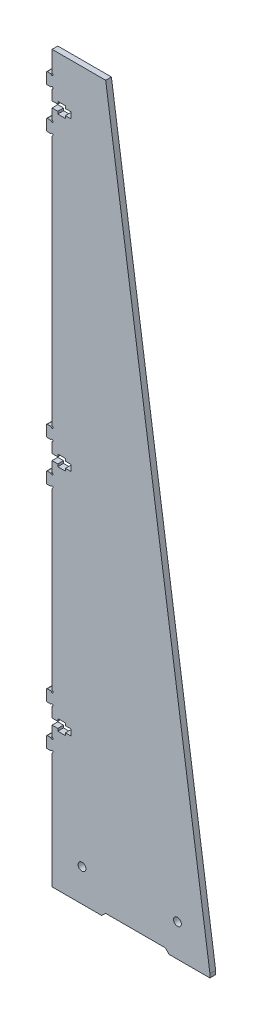
from build123d import *

# Parameters (mm, degrees)
MODEL_R                 = 2.05
SALIENTE_EXTRUIR1_DEPTH = 3


with BuildPart() as part:
    # Model → Saliente-Extruir1 (new body)
    with BuildSketch(Plane.XY):
        with BuildLine():
            Line((458.658091322, 643.996335498), (476.091013084, 643.996335498))
            Line((476.091013084, 643.996335498), (524.497055169, 308.953007972))
            Line((524.497055169, 308.953007972), (530.703308605, 265.996308498))
            Line((530.703308605, 265.996308498), (530.703308605, 263.996308498))
            Line((530.703308605, 263.996308498), (509.328287285, 263.996308498))
            Line((509.328287285, 263.996308498), (507.328283285, 265.996308498))
            Line((507.328283285, 265.996308498), (476.008092322, 265.996308498))
            Line((476.008092322, 265.996308498), (474.008092322, 263.996308498))
            Line((474.008092322, 263.996308498), (448.008092322, 263.996308498))
            Line((448.008092322, 263.996308498), (448.008095322, 324.530272498))
            ThreePointArc((448.008095322, 324.530272498), (448.075082188, 324.78027175), (448.258093826, 324.963284336))
            ThreePointArc((448.258093826, 324.963284336), (448.361645507, 325.749850684), (447.57507962, 325.646295498))
            ThreePointArc((447.57507962, 325.646295498), (447.39206666, 325.463282647), (447.142066322, 325.396295498))
            Line((447.142066322, 325.396295498), (445.508040322, 325.396292498))
            ThreePointArc((445.508040322, 325.396292498), (445.154486932, 325.542739108), (445.008040322, 325.896292498))
            Line((445.008040322, 325.896292498), (445.008040322, 330.896290498))
            ThreePointArc((445.008040322, 330.896290498), (445.154486932, 331.249843889), (445.508040322, 331.396290498))
            Line((445.508040322, 331.396290498), (447.142068322, 331.396290498))
            ThreePointArc((447.142068322, 331.396290498), (447.392067574, 331.329303632), (447.57508016, 331.146291995))
            ThreePointArc((447.57508016, 331.146291995), (448.361645749, 331.042740921), (448.258092322, 331.8293062))
            ThreePointArc((448.258092322, 331.8293062), (448.075079721, 332.012318727), (448.008092322, 332.262318498))
            Line((448.008092322, 332.262318498), (448.008092322, 337.396312498))
            Line((448.008092322, 337.396312498), (451.008064322, 337.396312498))
            Line((451.008064322, 337.396312498), (451.008064322, 336.121317498))
            Line((451.008064322, 336.121317498), (455.008092322, 336.121317498))
            Line((455.008092322, 336.121317498), (455.008092322, 337.396312498))
            Line((455.008092322, 337.396312498), (458.008092322, 337.396312498))
            Line((458.008092322, 337.396312498), (458.008092322, 340.596323498))
            Line((458.008092322, 340.596323498), (455.008092322, 340.596323498))
            Line((455.008092322, 340.596323498), (455.008092322, 341.871317498))
            Line((455.008092322, 341.871317498), (451.008064322, 341.871317498))
            Line((451.008064322, 341.871317498), (451.008064322, 340.596323498))
            Line((451.008064322, 340.596323498), (448.008092322, 340.596323498))
            Line((448.008092322, 340.596323498), (448.008095322, 345.730288498))
            ThreePointArc((448.008095322, 345.730288498), (448.075082188, 345.98028775), (448.258093826, 346.163300336))
            ThreePointArc((448.258093826, 346.163300336), (448.3616449, 346.949865925), (447.57507962, 346.846312498))
            ThreePointArc((447.57507962, 346.846312498), (447.39206666, 346.663299647), (447.142066322, 346.596312498))
            Line((447.142066322, 346.596312498), (445.508040322, 346.596309498))
            ThreePointArc((445.508040322, 346.596309498), (445.154486932, 346.742756108), (445.008040322, 347.096309498))
            Line((445.008040322, 347.096309498), (445.008040322, 352.096306498))
            ThreePointArc((445.008040322, 352.096306498), (445.154486932, 352.449859889), (445.508040322, 352.596306498))
            Line((445.508040322, 352.596306498), (447.142068322, 352.596306498))
            ThreePointArc((447.142068322, 352.596306498), (447.392067574, 352.529319632), (447.57508016, 352.346307995))
            ThreePointArc((447.57508016, 352.346307995), (448.361645749, 352.242756921), (448.258092322, 353.0293222))
            ThreePointArc((448.258092322, 353.0293222), (448.075079721, 353.212334727), (448.008092322, 353.462334498))
            Line((448.008092322, 353.462334498), (448.008095322, 353.464066546))
            Line((448.008095322, 353.464066546), (448.008095322, 444.530276498))
            ThreePointArc((448.008095322, 444.530276498), (448.075082188, 444.78027575), (448.258093826, 444.963288336))
            ThreePointArc((448.258093826, 444.963288336), (448.361645507, 445.749854684), (447.57507962, 445.646299498))
            ThreePointArc((447.57507962, 445.646299498), (447.39206666, 445.463286647), (447.142066322, 445.396299498))
            Line((447.142066322, 445.396299498), (445.508040322, 445.396296498))
            ThreePointArc((445.508040322, 445.396296498), (445.154486932, 445.542743108), (445.008040322, 445.896296498))
            Line((445.008040322, 445.896296498), (445.008040322, 450.896294498))
            ThreePointArc((445.008040322, 450.896294498), (445.154486932, 451.249847889), (445.508040322, 451.396294498))
            Line((445.508040322, 451.396294498), (447.142068322, 451.396294498))
            ThreePointArc((447.142068322, 451.396294498), (447.392067574, 451.329307632), (447.57508016, 451.146295995))
            ThreePointArc((447.57508016, 451.146295995), (448.361645749, 451.042744921), (448.258092322, 451.8293102))
            ThreePointArc((448.258092322, 451.8293102), (448.075079721, 452.012322727), (448.008092322, 452.262322498))
            Line((448.008092322, 452.262322498), (448.008092322, 457.396316498))
            Line((448.008092322, 457.396316498), (451.008064322, 457.396316498))
            Line((451.008064322, 457.396316498), (451.008064322, 456.121321498))
            Line((451.008064322, 456.121321498), (455.008092322, 456.121321498))
            Line((455.008092322, 456.121321498), (455.008092322, 457.396316498))
            Line((455.008092322, 457.396316498), (458.008092322, 457.396316498))
            Line((458.008092322, 457.396316498), (458.008092322, 460.596327498))
            Line((458.008092322, 460.596327498), (455.008092322, 460.596327498))
            Line((455.008092322, 460.596327498), (455.008092322, 461.871321498))
            Line((455.008092322, 461.871321498), (451.008064322, 461.871321498))
            Line((451.008064322, 461.871321498), (451.008064322, 460.596327498))
            Line((451.008064322, 460.596327498), (448.008092322, 460.596327498))
            Line((448.008092322, 460.596327498), (448.008095322, 465.730292498))
            ThreePointArc((448.008095322, 465.730292498), (448.075082188, 465.98029175), (448.258093826, 466.163304336))
            ThreePointArc((448.258093826, 466.163304336), (448.361645507, 466.949870684), (447.57507962, 466.846315498))
            ThreePointArc((447.57507962, 466.846315498), (447.39206666, 466.663302647), (447.142066322, 466.596315498))
            Line((447.142066322, 466.596315498), (445.508040322, 466.596312498))
            ThreePointArc((445.508040322, 466.596312498), (445.154486932, 466.742759108), (445.008040322, 467.096312498))
            Line((445.008040322, 467.096312498), (445.008040322, 472.096310498))
            ThreePointArc((445.008040322, 472.096310498), (445.154486932, 472.449863889), (445.508040322, 472.596310498))
            Line((445.508040322, 472.596310498), (447.142068322, 472.596310498))
            ThreePointArc((447.142068322, 472.596310498), (447.392067574, 472.529323632), (447.57508016, 472.346311995))
            ThreePointArc((447.57508016, 472.346311995), (448.361645749, 472.242760921), (448.258092322, 473.0293262))
            ThreePointArc((448.258092322, 473.0293262), (448.075081422, 473.212339245), (448.008095322, 473.462338498))
            Line((448.008095322, 473.462338498), (448.008095322, 473.464070546))
            Line((448.008095322, 473.464070546), (448.008095322, 604.530272498))
            ThreePointArc((448.008095322, 604.530272498), (448.075082188, 604.78027175), (448.258093826, 604.963284336))
            ThreePointArc((448.258093826, 604.963284336), (448.3616449, 605.749849925), (447.57507962, 605.646296498))
            ThreePointArc((447.57507962, 605.646296498), (447.39206666, 605.463283647), (447.142066322, 605.396296498))
            Line((447.142066322, 605.396296498), (445.508040322, 605.396293498))
            ThreePointArc((445.508040322, 605.396293498), (445.154486932, 605.542740108), (445.008040322, 605.896293498))
            Line((445.008040322, 605.896293498), (445.008040322, 610.896290498))
            ThreePointArc((445.008040322, 610.896290498), (445.154486932, 611.249843889), (445.508040322, 611.396290498))
            Line((445.508040322, 611.396290498), (447.142068322, 611.396290498))
            ThreePointArc((447.142068322, 611.396290498), (447.392067574, 611.329303632), (447.57508016, 611.146291995))
            ThreePointArc((447.57508016, 611.146291995), (448.361645749, 611.042740921), (448.258092322, 611.8293062))
            ThreePointArc((448.258092322, 611.8293062), (448.075079721, 612.012318727), (448.008092322, 612.262318498))
            Line((448.008092322, 612.262318498), (448.008092322, 617.396312498))
            Line((448.008092322, 617.396312498), (451.008064322, 617.396312498))
            Line((451.008064322, 617.396312498), (451.008064322, 616.121318498))
            Line((451.008064322, 616.121318498), (455.008092322, 616.121318498))
            Line((455.008092322, 616.121318498), (455.008092322, 617.396312498))
            Line((455.008092322, 617.396312498), (458.008092322, 617.396312498))
            Line((458.008092322, 617.396312498), (458.008092322, 620.596323498))
            Line((458.008092322, 620.596323498), (455.008092322, 620.596323498))
            Line((455.008092322, 620.596323498), (455.008092322, 621.871318498))
            Line((455.008092322, 621.871318498), (451.008064322, 621.871318498))
            Line((451.008064322, 621.871318498), (451.008064322, 620.596323498))
            Line((451.008064322, 620.596323498), (448.008092322, 620.596323498))
            Line((448.008092322, 620.596323498), (448.008095322, 625.730288498))
            ThreePointArc((448.008095322, 625.730288498), (448.075082188, 625.98028775), (448.258093826, 626.163300336))
            ThreePointArc((448.258093826, 626.163300336), (448.3616449, 626.949865925), (447.57507962, 626.846312498))
            ThreePointArc((447.57507962, 626.846312498), (447.39206666, 626.663299647), (447.142066322, 626.596312498))
            Line((447.142066322, 626.596312498), (445.508040322, 626.596309498))
            ThreePointArc((445.508040322, 626.596309498), (445.154486932, 626.742756108), (445.008040322, 627.096309498))
            Line((445.008040322, 627.096309498), (445.008040322, 632.096306498))
            ThreePointArc((445.008040322, 632.096306498), (445.154486932, 632.449859889), (445.508040322, 632.596306498))
            Line((445.508040322, 632.596306498), (447.142068322, 632.596306498))
            ThreePointArc((447.142068322, 632.596306498), (447.392067574, 632.529319632), (447.57508016, 632.346307995))
            ThreePointArc((447.57508016, 632.346307995), (448.361645749, 632.242756921), (448.258092322, 633.0293222))
            ThreePointArc((448.258092322, 633.0293222), (448.075079471, 633.21233516), (448.008092322, 633.462335498))
            Line((448.008092322, 633.462335498), (448.008092322, 643.996335498))
            Line((448.008092322, 643.996335498), (458.658091322, 643.996335498))
        make_face()
        with Locations((463.687972981, 280.996308498)):
            Circle(MODEL_R, mode=Mode.SUBTRACT)
        with Locations((513.687972981, 280.996308498)):
            Circle(MODEL_R, mode=Mode.SUBTRACT)
    extrude(amount=SALIENTE_EXTRUIR1_DEPTH)


solid = part.part
